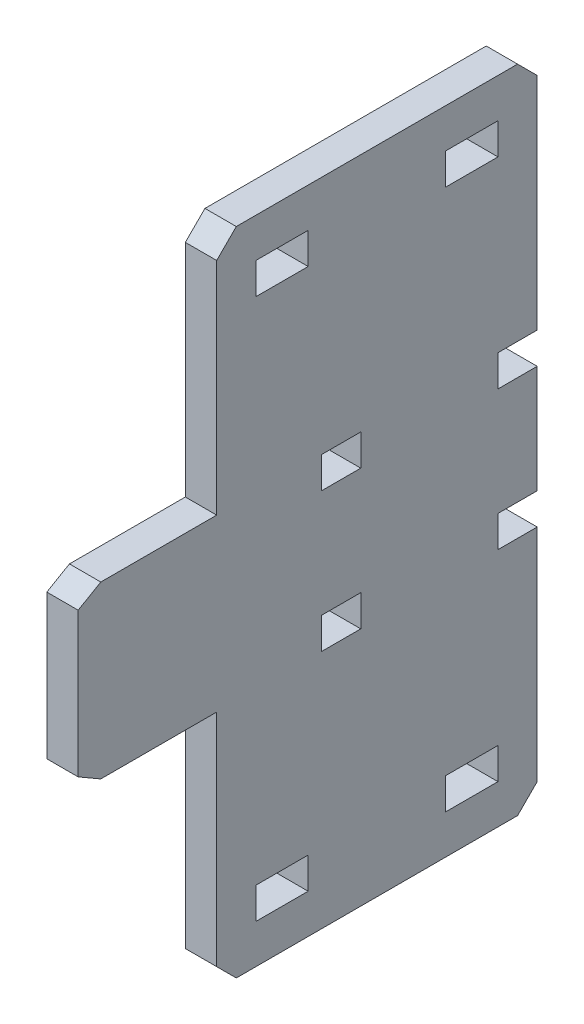
from build123d import *

# Parameters (mm, degrees)
SKETCH1_W           = 10.16
SKETCH1_H           = 6.096
SKETCH1_W_2         = 7.62
BOSS_EXTRUDE1_DEPTH = 3.048
CHAMFER2_SIZE       = 3.81


with BuildPart() as part:
    # Sketch1 → Boss-Extrude1 (new, symmetric)
    with BuildSketch(Plane(origin=(0, 0, 0), x_dir=(0, 0, -1), z_dir=(1, 0, 0))):
        Polygon((45.72, -63.246), (45.72, -16.5735), (38.1, -16.5735), (38.1, -10.4775), (45.72, -10.4775), (45.72, 10.4775), (38.1, 10.4775), (38.1, 16.5735), (45.72, 16.5735), (45.72, 63.246), (-16.571856626, 63.246), (-16.571856626, 16.5735), (-39.096447575, 16.5735), (-43.495856626, 14.0335), (-43.495856626, -14.0335), (-39.096447575, -16.5735), (-16.571856626, -16.5735), (-16.571856626, -63.246), align=None)
        with Locations((33.02, -52.578)):
            Rectangle(SKETCH1_W, SKETCH1_H, mode=Mode.SUBTRACT)
        with Locations((33.02, 52.578)):
            Rectangle(SKETCH1_W, SKETCH1_H, mode=Mode.SUBTRACT)
        with Locations((-3.871856626, 52.578)):
            Rectangle(SKETCH1_W, SKETCH1_H, mode=Mode.SUBTRACT)
        with Locations((-3.871856626, -52.578)):
            Rectangle(SKETCH1_W, SKETCH1_H, mode=Mode.SUBTRACT)
        with Locations((7.62, 13.5255)):
            Rectangle(SKETCH1_W_2, SKETCH1_H, mode=Mode.SUBTRACT)
        with Locations((7.62, -13.5255)):
            Rectangle(SKETCH1_W_2, SKETCH1_H, mode=Mode.SUBTRACT)
    extrude(amount=BOSS_EXTRUDE1_DEPTH, both=True)

    # Chamfer2
    chamfer2_edges = [part.edges().sort_by_distance(p)[0] for p in [
        (0, -63.246, -45.72),
        (0, -63.246, 16.571856626),
        (0, 63.246, -45.72),
        (0, 63.246, 16.571856626),
    ]]
    chamfer(chamfer2_edges, length=CHAMFER2_SIZE)


solid = part.part
